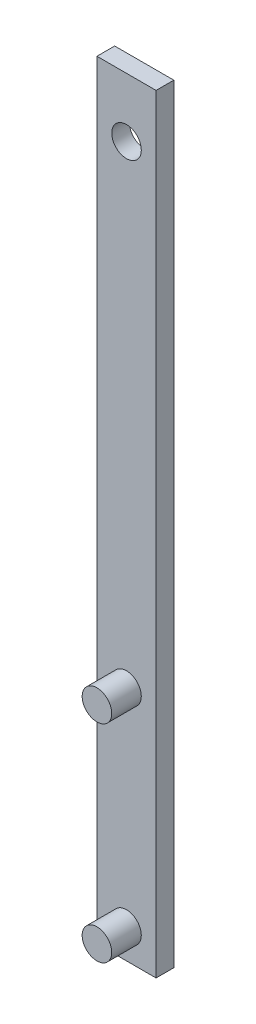
from build123d import *

# Parameters (mm, degrees)
ESBO_O1_W                = 10
ESBO_O1_H                = 130
ESBO_O1_R                = 2.5
RESSALTO_EXTRUS_O1_DEPTH = 3
ESBO_O1_11_R             = 2.5
RESSALTO_EXTRUS_O7_DEPTH = 8


with BuildPart() as part:
    # Esboço1 → Ressalto-extrusão1 (new body)
    with BuildSketch(Plane.XY):
        Rectangle(ESBO_O1_W, ESBO_O1_H)
        with Locations((0, 55)):
            Circle(ESBO_O1_R, mode=Mode.SUBTRACT)
        with Locations((0, -60)):
            Circle(ESBO_O1_R, mode=Mode.SUBTRACT)
        with Locations((0, -25)):
            Circle(ESBO_O1_R, mode=Mode.SUBTRACT)
    extrude(amount=RESSALTO_EXTRUS_O1_DEPTH)

    # Esboço1<11> → Ressalto-extrusão7 (add)
    with BuildSketch(Plane.XY):
        with Locations((0, -60)):
            Circle(ESBO_O1_11_R)
        with Locations((0, -25)):
            Circle(ESBO_O1_11_R)
    extrude(amount=RESSALTO_EXTRUS_O7_DEPTH)


solid = part.part
